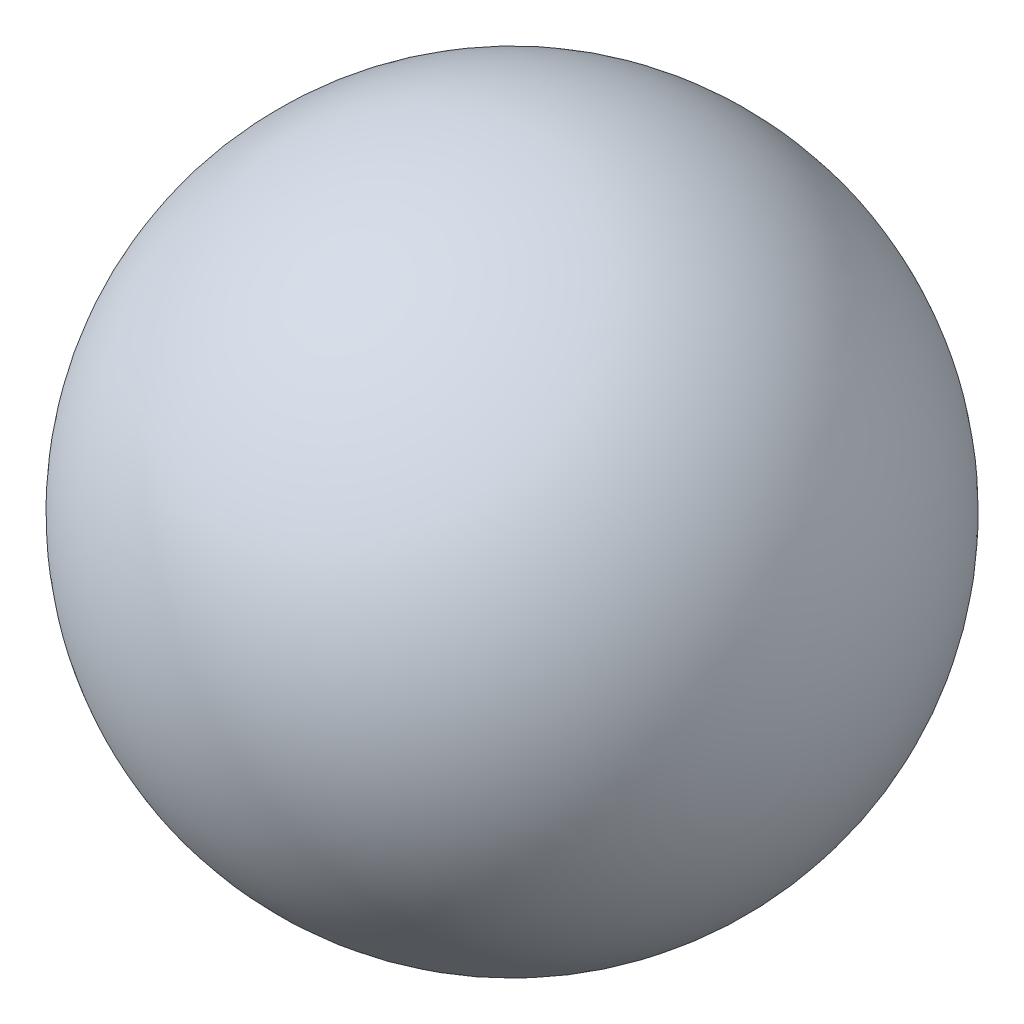
from build123d import *


with BuildPart() as part:
    # Sketch1 → Revolve1 (revolve)
    with BuildSketch(Plane(origin=(0, 0, 0), x_dir=(1, 0, 0), z_dir=(0, 1, 0))):
        with BuildLine():
            Line((0, 0), (0, 609.6))
            ThreePointArc((0, 609.6), (304.8, 304.8), (0, 0))
        make_face()
    revolve(axis=Axis((0, 0, 0), (0, 0, -1)))


solid = part.part
